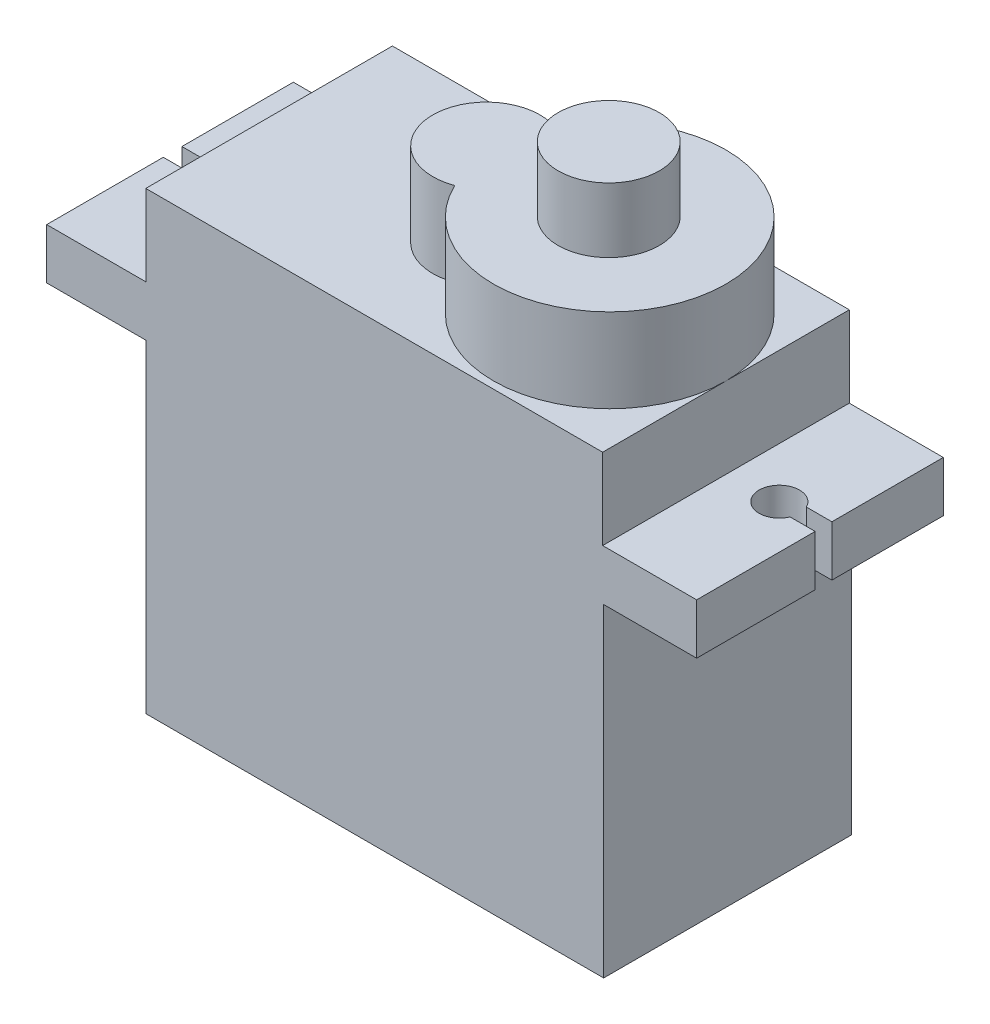
from build123d import *

# Parameters (mm, degrees)
SKETCH1_W           = 22.65
SKETCH1_H           = 12.25
BOSS_EXTRUDE1_DEPTH = 16
SKETCH2_W           = 32.15
SKETCH2_H           = 12.2
BOSS_EXTRUDE2_DEPTH = 2.5
SKETCH3_W           = 22.6
SKETCH3_H           = 12.2
BOSS_EXTRUDE3_DEPTH = 4
BOSS_EXTRUDE4_DEPTH = 4.15
SKETCH5_R           = 2.5
BOSS_EXTRUDE5_DEPTH = 3.2
CUT_EXTRUDE1_DEPTH  = 19.5


with BuildPart() as part:
    # Sketch1 → Boss-Extrude1 (new body)
    with BuildSketch(Plane(origin=(0, 0, 0), x_dir=(1, 0, 0), z_dir=(0, 1, 0))):
        with Locations((11.325, 6.125)):
            Rectangle(SKETCH1_W, SKETCH1_H)
    extrude(amount=BOSS_EXTRUDE1_DEPTH)

    # Sketch2 → Boss-Extrude2 (add)
    with BuildSketch(Plane(origin=(0, 16, 0), x_dir=(1, 0, 0), z_dir=(0, 1, 0))):
        with Locations((11.175, 6.1)):
            Rectangle(SKETCH2_W, SKETCH2_H)
    extrude(amount=BOSS_EXTRUDE2_DEPTH)

    # Sketch3 → Boss-Extrude3 (add)
    with BuildSketch(Plane(origin=(0, 18.5, 0), x_dir=(1, 0, 0), z_dir=(0, 1, 0))):
        with Locations((11.3, 6.1)):
            Rectangle(SKETCH3_W, SKETCH3_H)
    extrude(amount=BOSS_EXTRUDE3_DEPTH)

    # Sketch4 → Boss-Extrude4 (add)
    with BuildSketch(Plane(origin=(0, 22.5, 0), x_dir=(1, 0, 0), z_dir=(0, 1, 0))):
        with BuildLine():
            ThreePointArc((11.66557377, 3.61318986), (22.6, 6.1), (11.66557377, 8.58681014))
            ThreePointArc((11.66557377, 8.58681014), (8.1, 6.1), (11.66557377, 3.61318986))
        make_face()
    extrude(amount=BOSS_EXTRUDE4_DEPTH)

    # Sketch5 → Boss-Extrude5 (add)
    with BuildSketch(Plane(origin=(0, 26.65, 0), x_dir=(1, 0, 0), z_dir=(0, 1, 0))):
        with Locations((16.8, 6.1)):
            Circle(SKETCH5_R)
    extrude(amount=BOSS_EXTRUDE5_DEPTH)

    # Sketch6 → Cut-Extrude1 (cut, through all)
    with BuildSketch(Plane(origin=(0, 18.5, 0), x_dir=(1, 0, 0), z_dir=(0, 1, 0))):
        with BuildLine():
            Line((-3.615686095, 5.766143081), (-4.9, 5.766143081))
            Line((-4.9, 5.766143081), (-4.9, 6.689056169))
            Line((-4.9, 6.689056169), (-3.63798195, 6.689056169))
            ThreePointArc((-3.63798195, 6.689056169), (-1.74029168, 6.273174961), (-3.615686095, 5.766143081))
        make_face()
        with BuildLine():
            Line((26.012019834, 5.861881235), (27.25, 5.861881235))
            Line((27.25, 5.861881235), (27.25, 6.689056169))
            Line((27.25, 6.689056169), (25.98798195, 6.689056169))
            ThreePointArc((25.98798195, 6.689056169), (24.090421981, 6.219975921), (26.012019834, 5.861881235))
        make_face()
    extrude(amount=-CUT_EXTRUDE1_DEPTH, mode=Mode.SUBTRACT)


solid = part.part
